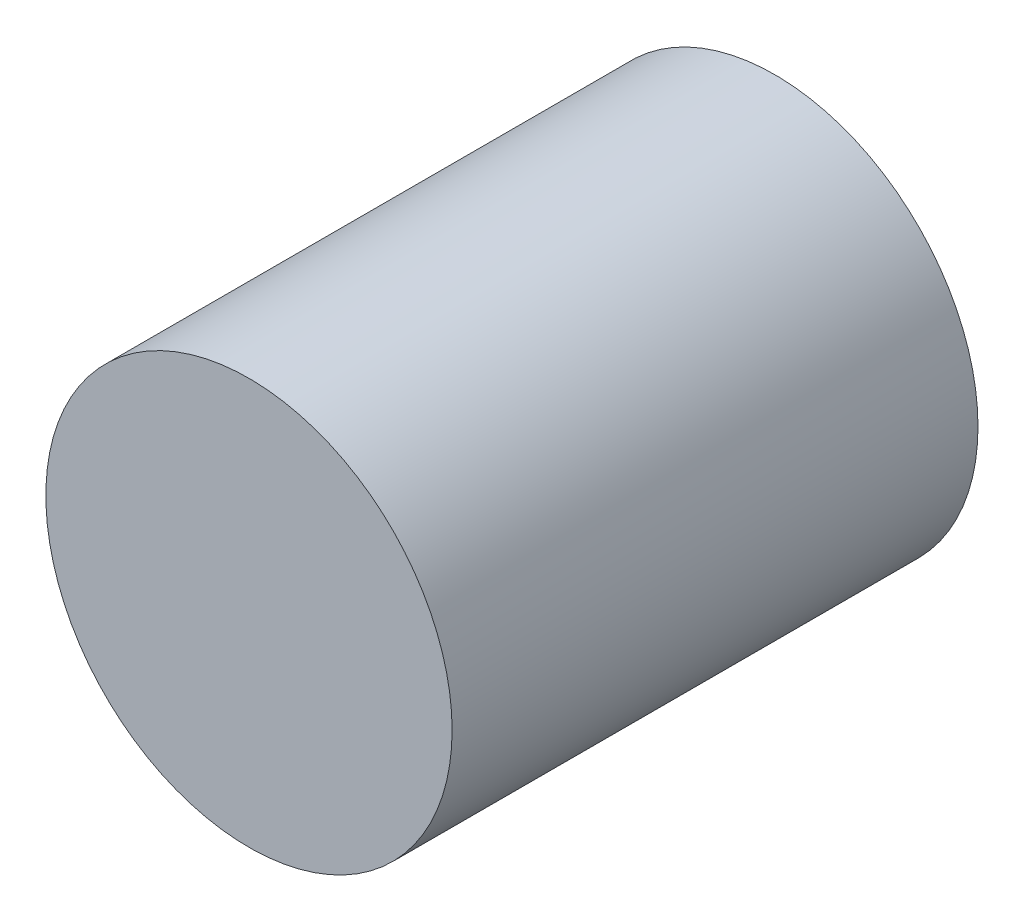
from build123d import *

# Parameters (mm, degrees)
SKETCH1_R           = 1.143
BOSS_EXTRUDE1_DEPTH = 2.9591


with BuildPart() as part:
    # Sketch1 → Boss-Extrude1 (new body)
    with BuildSketch(Plane.XY):
        Circle(SKETCH1_R)
    extrude(amount=BOSS_EXTRUDE1_DEPTH)


solid = part.part
